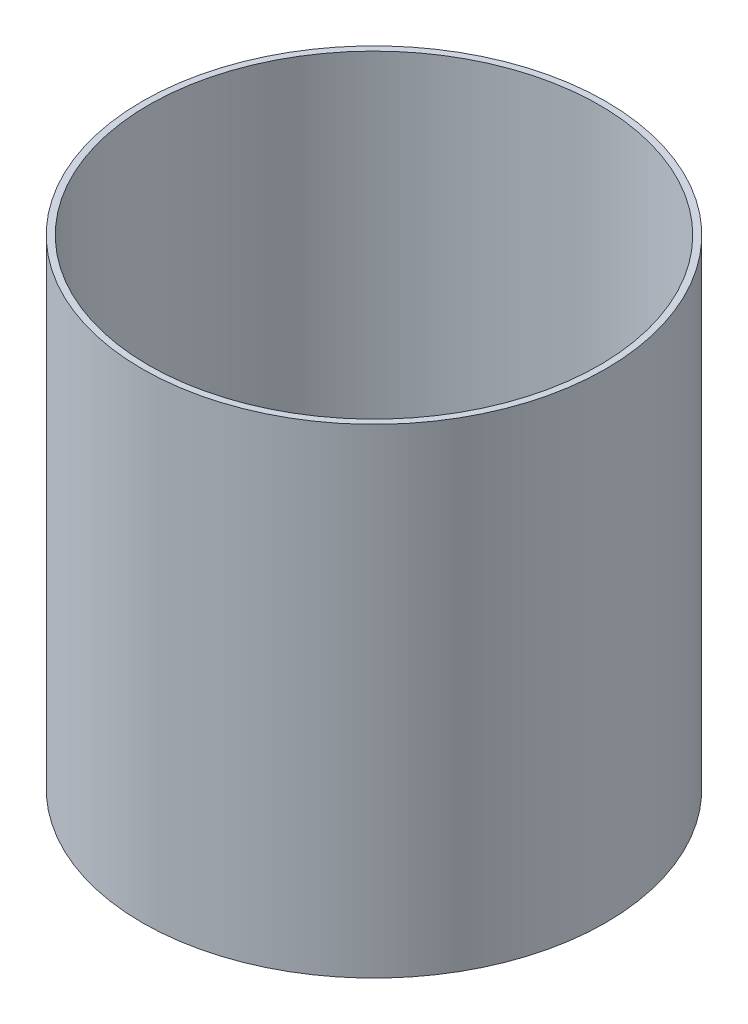
from build123d import *

# Parameters (mm, degrees)
SKETCH1_R           = 145
SKETCH1_R_2         = 141
BOSS_EXTRUDE1_DEPTH = 300


with BuildPart() as part:
    # Sketch1 → Boss-Extrude1 (new body)
    with BuildSketch(Plane(origin=(0, 0, 0), x_dir=(1, 0, 0), z_dir=(0, 1, 0))):
        Circle(SKETCH1_R)
        Circle(SKETCH1_R_2, mode=Mode.SUBTRACT)
    extrude(amount=-BOSS_EXTRUDE1_DEPTH)


solid = part.part
